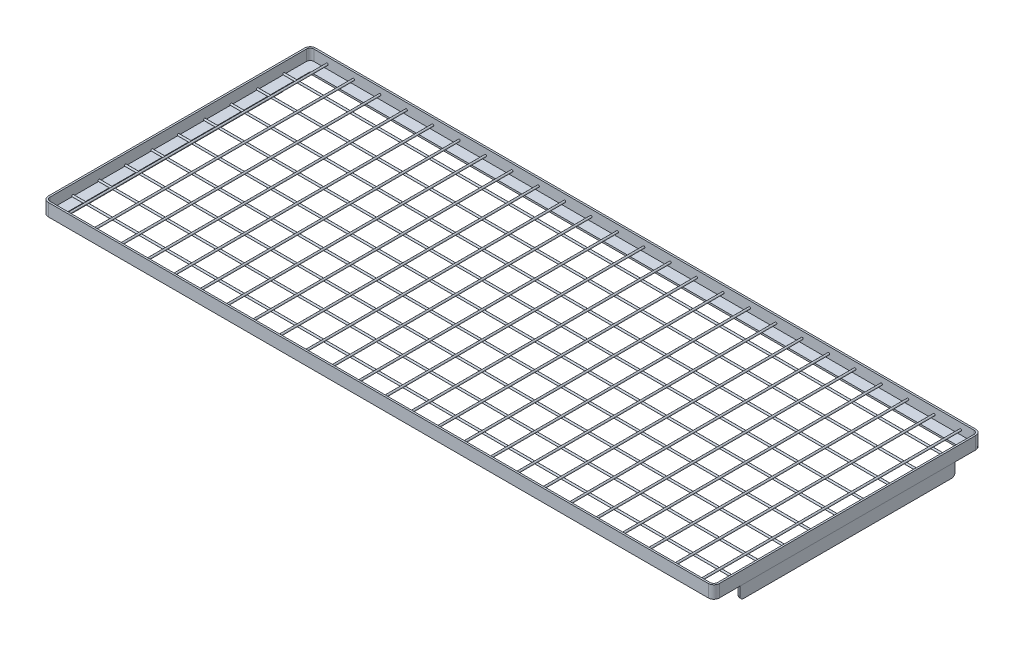
from build123d import *

# Parameters (mm, degrees)
BOSS_EXTRUDE1_DEPTH  = 21.844
SKETCH3_W            = 1305.687
SKETCH3_H            = 489.712
BOSS_EXTRUDE2_DEPTH  = 3.556
SKETCH10_R           = 1.905
BOSS_EXTRUDE13_DEPTH = 1349.375
LPATTERN1_COUNT      = 5
LPATTERN1_PITCH      = 53.34
LPATTERN1_COL_COUNT  = 5
LPATTERN1_COL_PITCH  = 53.34
SKETCH8_W            = 434.975
SKETCH8_H            = 25.4
BOSS_EXTRUDE11_DEPTH = 3.556
SKETCH11_R           = 1.905
BOSS_EXTRUDE14_DEPTH = 533.4
LPATTERN2_COUNT      = 13
LPATTERN2_PITCH      = 53.34
LPATTERN2_COL_COUNT  = 13
LPATTERN2_COL_PITCH  = 53.34
SKETCH9_W            = 434.975
SKETCH9_H            = 25.4
BOSS_EXTRUDE12_DEPTH = 3.556
FILLET1_R            = 7.62
FILLET2_R            = 7.62


with BuildPart() as part:
    # Sketch1 → Boss-Extrude1 (new body)
    with BuildSketch(Plane(origin=(0, 0, 0), x_dir=(1, 0, 0), z_dir=(0, 1, 0))):
        with BuildLine():
            Line((-667.0675, -270.256), (667.0675, -270.256))
            ThreePointArc((667.0675, -270.256), (674.970125387, -266.982625387), (678.2435, -259.08))
            Line((678.2435, -259.08), (678.2435, 259.08))
            ThreePointArc((678.2435, 259.08), (674.970125387, 266.982625387), (667.0675, 270.256))
            Line((667.0675, 270.256), (-667.0675, 270.256))
            ThreePointArc((-667.0675, 270.256), (-674.970125387, 266.982625387), (-678.2435, 259.08))
            Line((-678.2435, 259.08), (-678.2435, -259.08))
            ThreePointArc((-678.2435, -259.08), (-674.970125387, -266.982625387), (-667.0675, -270.256))
        make_face()
        with BuildLine():
            Line((-667.0675, -266.7), (667.0675, -266.7))
            ThreePointArc((667.0675, -266.7), (672.455653673, -264.468153673), (674.6875, -259.08))
            Line((674.6875, -259.08), (674.6875, 259.08))
            ThreePointArc((674.6875, 259.08), (672.455653673, 264.468153673), (667.0675, 266.7))
            Line((667.0675, 266.7), (-667.0675, 266.7))
            ThreePointArc((-667.0675, 266.7), (-672.455653673, 264.468153673), (-674.6875, 259.08))
            Line((-674.6875, 259.08), (-674.6875, -259.08))
            ThreePointArc((-674.6875, -259.08), (-672.455653673, -264.468153673), (-667.0675, -266.7))
        make_face(mode=Mode.SUBTRACT)
    extrude(amount=BOSS_EXTRUDE1_DEPTH)

    # Sketch3 → Boss-Extrude2 (add)
    with BuildSketch(Plane.XZ):
        with BuildLine():
            Line((-667.0675, 270.256), (667.0675, 270.256))
            ThreePointArc((667.0675, 270.256), (674.970125387, 266.982625387), (678.2435, 259.08))
            Line((678.2435, 259.08), (678.2435, -259.08))
            ThreePointArc((678.2435, -259.08), (674.970125387, -266.982625387), (667.0675, -270.256))
            Line((667.0675, -270.256), (-667.0675, -270.256))
            ThreePointArc((-667.0675, -270.256), (-674.970125387, -266.982625387), (-678.2435, -259.08))
            Line((-678.2435, -259.08), (-678.2435, 259.08))
            ThreePointArc((-678.2435, 259.08), (-674.970125387, 266.982625387), (-667.0675, 270.256))
        make_face()
        Rectangle(SKETCH3_W, SKETCH3_H, mode=Mode.SUBTRACT)
    extrude(amount=BOSS_EXTRUDE2_DEPTH)

    # Sketch10 → Boss-Extrude13 (add)
    with BuildSketch(Plane(origin=(-674.6875, 0, 0), x_dir=(0, 0, -1), z_dir=(1, 0, 0))):
        with Locations((0, 1.524)):
            Circle(SKETCH10_R)
    boss_extrude13 = extrude(amount=BOSS_EXTRUDE13_DEPTH)

    # LPattern1: Boss-Extrude13 ×5
    with Locations(*[(0, 0, i * LPATTERN1_PITCH) for i in range(1, LPATTERN1_COUNT)]):
        add(boss_extrude13)

    # LPattern1 col: Boss-Extrude13 ×5
    with Locations(*[(0, 0, -i * LPATTERN1_COL_PITCH) for i in range(1, LPATTERN1_COL_COUNT)]):
        add(boss_extrude13)

    # Sketch11 → Boss-Extrude14 (add)
    with BuildSketch(Plane(origin=(0, 0, 266.7), x_dir=(-1, 0, 0), z_dir=(0, 0, -1))):
        with Locations((0, 8.89)):
            Circle(SKETCH11_R)
    boss_extrude14 = extrude(amount=BOSS_EXTRUDE14_DEPTH)

    # LPattern2: Boss-Extrude14 ×13
    with Locations(*[(-i * LPATTERN2_PITCH, 0, 0) for i in range(1, LPATTERN2_COUNT)]):
        add(boss_extrude14)

    # LPattern2 col: Boss-Extrude14 ×13
    with Locations(*[(i * LPATTERN2_COL_PITCH, 0, 0) for i in range(1, LPATTERN2_COL_COUNT)]):
        add(boss_extrude14)


with BuildPart() as body_2:
    # Sketch8 → Boss-Extrude11 (new body)
    with BuildSketch(Plane.ZY.offset(678.2435)):
        with Locations((0, -16.256)):
            Rectangle(SKETCH8_W, SKETCH8_H)
    extrude(amount=-BOSS_EXTRUDE11_DEPTH)

    # Fillet1
    fillet1_edges = [body_2.edges().sort_by_distance(p)[0] for p in [
        (-676.4655, -28.956, 217.4875),
        (-676.4655, -28.956, -217.4875),
    ]]
    fillet(fillet1_edges, radius=FILLET1_R)


with BuildPart() as body_3:
    # Sketch9 → Boss-Extrude12 (new body)
    with BuildSketch(Plane(origin=(678.2435, 0, 0), x_dir=(0, 0, -1), z_dir=(1, 0, 0))):
        with Locations((0, -16.256)):
            Rectangle(SKETCH9_W, SKETCH9_H)
    extrude(amount=-BOSS_EXTRUDE12_DEPTH)

    # Fillet2
    fillet2_edges = [body_3.edges().sort_by_distance(p)[0] for p in [
        (676.4655, -28.956, -217.4875),
        (676.4655, -28.956, 217.4875),
    ]]
    fillet(fillet2_edges, radius=FILLET2_R)


solid = Compound([part.part, body_2.part, body_3.part])
